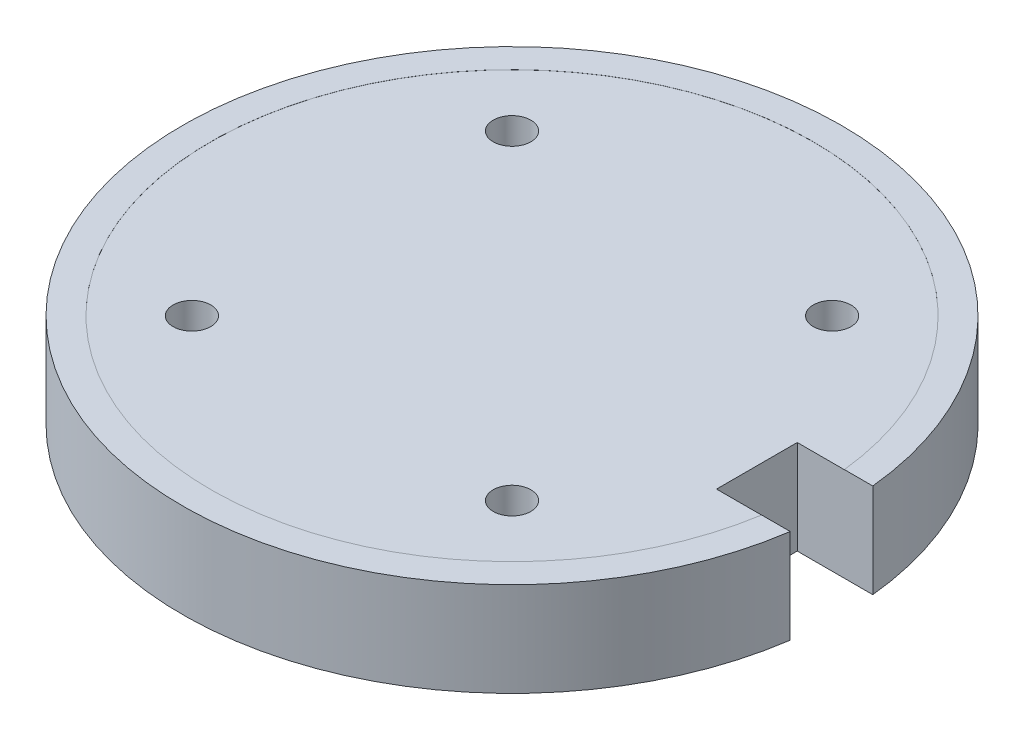
from build123d import *

# Parameters (mm, degrees)
SKETCH1_R               = 35
BOSS_EXTRUDE1_DEPTH     = 10
SKETCH27_W              = 8.45046724
SKETCH27_H              = 8.572937779
CUT_EXTRUDE8_DEPTH      = 11
SKETCH34_R              = 2
CUT_EXTRUDE9_DEPTH      = 1
CUT_EXTRUDE9_DEPTH_BACK = 11
SKETCH35_R              = 2
CUT_EXTRUDE10_DEPTH     = 11
SKETCH36_R              = 2
CUT_EXTRUDE11_DEPTH     = 11
SKETCH37_R              = 2
CUT_EXTRUDE12_DEPTH     = 11
SKETCH39_R              = 32
CUT_EXTRUDE14_DEPTH     = 0.01


with BuildPart() as part:
    # Sketch1 → Boss-Extrude1 (new body)
    with BuildSketch(Plane(origin=(0, 0, 0), x_dir=(1, 0, 0), z_dir=(0, 1, 0))):
        Circle(SKETCH1_R)
    extrude(amount=BOSS_EXTRUDE1_DEPTH)

    # Sketch27 → Cut-Extrude8 (cut, through all)
    with BuildSketch(Plane(origin=(0, 10, 0), x_dir=(1, 0, 0), z_dir=(0, 1, 0))):
        with Locations((31.027560582, -0.794372815)):
            Rectangle(SKETCH27_W, SKETCH27_H)
    extrude(amount=-CUT_EXTRUDE8_DEPTH, mode=Mode.SUBTRACT)

    # Sketch34 → Cut-Extrude9 (cut, two sides)
    with BuildSketch(Plane(origin=(0, 10, 0), x_dir=(1, 0, 0), z_dir=(0, 1, 0))) as cut_extrude9_sk:
        with Locations((-17, 17)):
            Circle(SKETCH34_R)
    extrude(amount=CUT_EXTRUDE9_DEPTH, mode=Mode.SUBTRACT)
    extrude(cut_extrude9_sk.sketch, amount=-CUT_EXTRUDE9_DEPTH_BACK, mode=Mode.SUBTRACT)

    # Sketch35 → Cut-Extrude10 (cut, through all)
    with BuildSketch(Plane(origin=(0, 0, 0), x_dir=(-1, 0, 0), z_dir=(0, -1, 0))):
        with Locations((-17, 17)):
            Circle(SKETCH35_R)
    extrude(amount=-CUT_EXTRUDE10_DEPTH, mode=Mode.SUBTRACT)

    # Sketch36 → Cut-Extrude11 (cut, through all)
    with BuildSketch(Plane(origin=(0, 0, 0), x_dir=(-1, 0, 0), z_dir=(0, -1, 0))):
        with Locations((17, -17)):
            Circle(SKETCH36_R)
    extrude(amount=-CUT_EXTRUDE11_DEPTH, mode=Mode.SUBTRACT)

    # Sketch37 → Cut-Extrude12 (cut, through all)
    with BuildSketch(Plane.XZ):
        with Locations((17, 17)):
            Circle(SKETCH37_R)
    extrude(amount=-CUT_EXTRUDE12_DEPTH, mode=Mode.SUBTRACT)

    # Sketch39 → Cut-Extrude14 (cut)
    with BuildSketch(Plane(origin=(0, 10, 0), x_dir=(1, 0, 0), z_dir=(0, 1, 0))):
        Circle(SKETCH39_R)
    extrude(amount=-CUT_EXTRUDE14_DEPTH, mode=Mode.SUBTRACT)


solid = part.part
